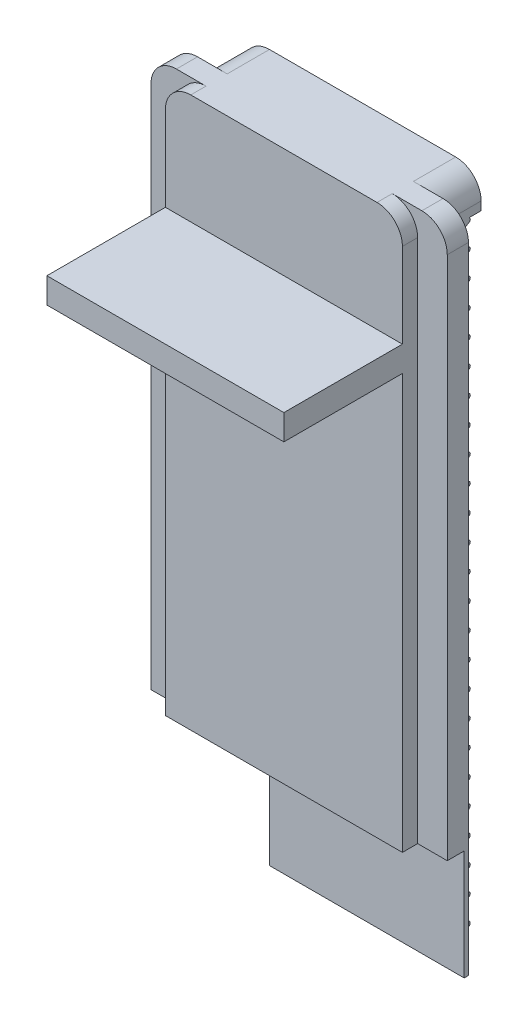
from build123d import *

# Parameters (mm, degrees)
ESBO_O1_W                = 28
ESBO_O1_H                = 78
RESSALTO_EXTRUS_O1_DEPTH = 3.2
RESSALTO_EXTRUS_O3_DEPTH = 28
PADR_O_LINEAR1_COUNT     = 25
PADR_O_LINEAR1_PITCH     = 3
RESSALTO_EXTRUS_O4_DEPTH = 78
ESBO_O7_W                = 28
ESBO_O7_H                = 73
CORTE_EXTRUS_O1_DEPTH    = 1.2
ESBO_O8_W                = 28
ESBO_O8_H                = 4
RESSALTO_EXTRUS_O5_DEPTH = 3.5
FILETE1_R                = 3
CORTE_EXTRUS_O2_DEPTH    = 13
ESBO_O11_W               = 15.8
ESBO_O11_H               = 3
RESSALTO_EXTRUS_O6_DEPTH = 28


with BuildPart() as part:
    # Esboço1 → Ressalto-extrusão1 (new body)
    with BuildSketch(Plane.XY):
        with Locations((0, 39)):
            Rectangle(ESBO_O1_W, ESBO_O1_H)
    extrude(amount=RESSALTO_EXTRUS_O1_DEPTH)

    # Esboço3 → Ressalto-extrusão3 (add)
    with BuildSketch(Plane.ZY.offset(14)):
        with BuildLine():
            Line((-0.145651273, 0.357247878), (-2.071253537, 1.512609236))
            ThreePointArc((-2.071253537, 1.512609236), (-2.216904811, 1.769857114), (-2.071253537, 2.027104991))
            Line((-2.071253537, 2.027104991), (-0.145651273, 3.18246635))
            ThreePointArc((-0.145651273, 3.18246635), (-0.038940028, 3.291904583), (0, 3.439714227))
            Line((0, 3.439714227), (0, 3.539714227))
            Line((0, 3.539714227), (0.2, 3.539714227))
            Line((0.2, 3.539714227), (0.2, 0))
            Line((0.2, 0), (0, 0))
            Line((0, 0), (0, 0.1))
            ThreePointArc((0, 0.1), (-0.038940028, 0.247809644), (-0.145651273, 0.357247878))
        make_face()
    ressalto_extrus_o3 = extrude(amount=-RESSALTO_EXTRUS_O3_DEPTH)

    # Padrão linear1: Ressalto-extrusão3 ×25
    with Locations(*[(0, i * PADR_O_LINEAR1_PITCH, 0) for i in range(1, PADR_O_LINEAR1_COUNT)]):
        add(ressalto_extrus_o3)

    # Esboço6 → Ressalto-extrusão4 (add)
    with BuildSketch(Plane(origin=(0, 78, 0), x_dir=(1, 0, 0), z_dir=(0, 1, 0))):
        Polygon((0, 0), (-14, 0), (-14, -1.5), (-17.5, -1.5), (-17.5, -4), (-14, -4), (-14, -7), (14, -7), (14, -4), (17.5, -4), (17.5, -1.5), (14, -1.5), (14, 0), align=None)
    extrude(amount=-RESSALTO_EXTRUS_O4_DEPTH)

    # Esboço7 → Corte-extrusão1 (cut)
    with BuildSketch(Plane.XY.offset(7)):
        with Locations((0, 41.5)):
            Rectangle(ESBO_O7_W, ESBO_O7_H)
    extrude(amount=-CORTE_EXTRUS_O1_DEPTH, mode=Mode.SUBTRACT)

    # Esboço8 → Ressalto-extrusão5 (add)
    with BuildSketch(Plane(origin=(0, 0, 0), x_dir=(-1, 0, 0), z_dir=(0, 0, -1))):
        with Locations((0, 76)):
            Rectangle(ESBO_O8_W, ESBO_O8_H)
    extrude(amount=RESSALTO_EXTRUS_O5_DEPTH)

    # Filete1
    filete1_edges = [part.edges().sort_by_distance(p)[0] for p in [
        (-14, 78, -1),
        (14, 78, -1),
        (-17.5, 78, 2.75),
        (-14, 78, 4.9),
        (14, 78, 4.9),
        (17.5, 78, 2.75),
    ]]
    fillet(filete1_edges, radius=FILETE1_R)

    # Esboço9 → Corte-extrusão2 (cut)
    with BuildSketch(Plane.XZ):
        Polygon((17.5, 2), (-5.5, 2), (-5.5, -3.5), (-17.5, -3.5), (-17.5, 8.294540238), (17.5, 8.294540238), align=None)
    extrude(amount=-CORTE_EXTRUS_O2_DEPTH, mode=Mode.SUBTRACT)

    # Esboço11 → Ressalto-extrusão6 (add)
    with BuildSketch(Plane.ZY.offset(14)):
        with Locations((11.9, 63.5)):
            Rectangle(ESBO_O11_W, ESBO_O11_H)
    extrude(amount=-RESSALTO_EXTRUS_O6_DEPTH)


solid = part.part
